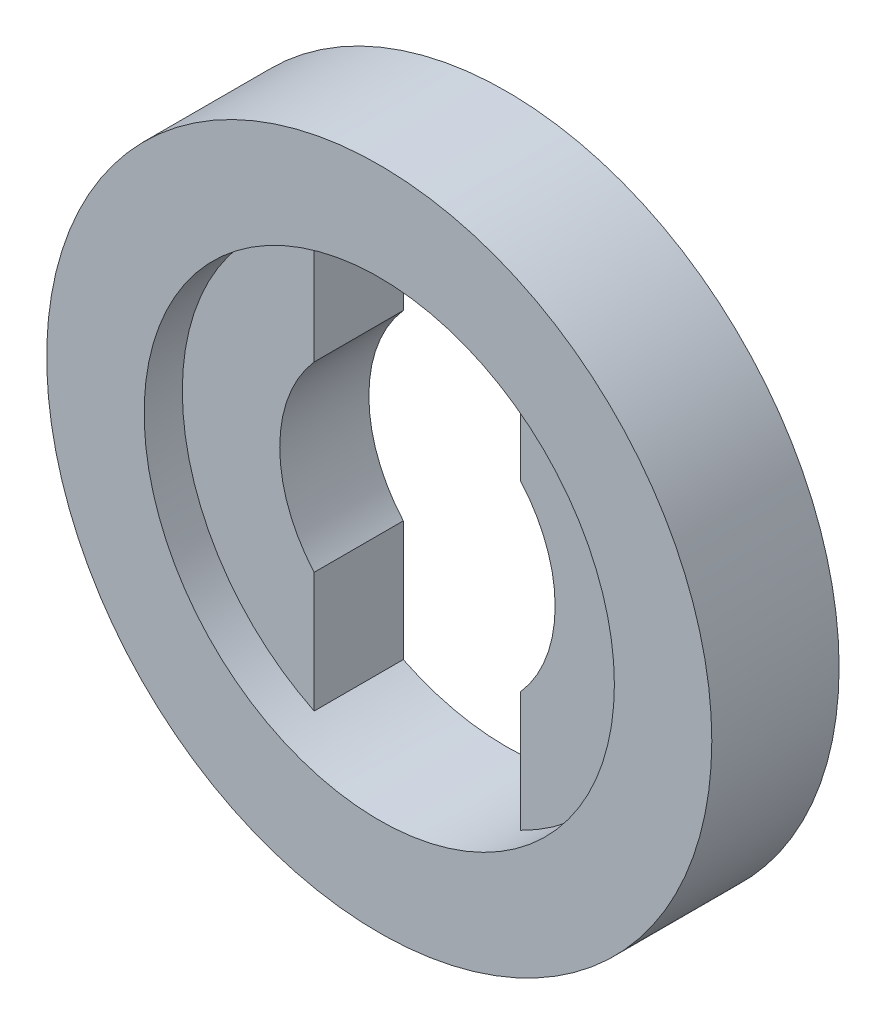
from build123d import *

# Parameters (mm, degrees)
SKETCH1_R          = 3.2512
SKETCH1_R_2        = 1.3462
EXTRUDE1_DEPTH     = 0.6223
SKETCH2_R          = 2.2987
CUT_EXTRUDE1_DEPTH = 0.37338
CUT_EXTRUDE2_DEPTH = 1.87122
CIRPATTERN1_COUNT  = 2


with BuildPart() as part:
    # Sketch1 → Extrude1 (new body, symmetric)
    with BuildSketch(Plane.XY):
        Circle(SKETCH1_R)
        Circle(SKETCH1_R_2, mode=Mode.SUBTRACT)
    extrude(amount=EXTRUDE1_DEPTH, both=True)

    # Sketch2 → Cut-Extrude1 (cut)
    with BuildSketch(Plane.XY.offset(0.6223)):
        Circle(SKETCH2_R)
    extrude(amount=-CUT_EXTRUDE1_DEPTH, mode=Mode.SUBTRACT)

    # Sketch3 → Cut-Extrude2 (cut, through all)
    with BuildSketch(Plane.XY.offset(0.24892)):
        with BuildLine():
            Line((-1.00965, 2.065097714), (-1.00965, 0.890427604))
            ThreePointArc((-1.00965, 0.890427604), (0, 1.3462), (1.00965, 0.890427604))
            Line((1.00965, 0.890427604), (1.00965, 2.065097714))
            ThreePointArc((1.00965, 2.065097714), (0, 2.2987), (-1.00965, 2.065097714))
        make_face()
    cut_extrude2 = extrude(amount=-CUT_EXTRUDE2_DEPTH, mode=Mode.SUBTRACT)

    # CirPattern1: Cut-Extrude2 ×2 about axis
    cirpattern1_axis = Axis((0, 0, 0.6223), (0, 0, -1))
    for i in range(1, CIRPATTERN1_COUNT):
        add(cut_extrude2.rotate(cirpattern1_axis, i * 360 / CIRPATTERN1_COUNT), mode=Mode.SUBTRACT)


solid = part.part
